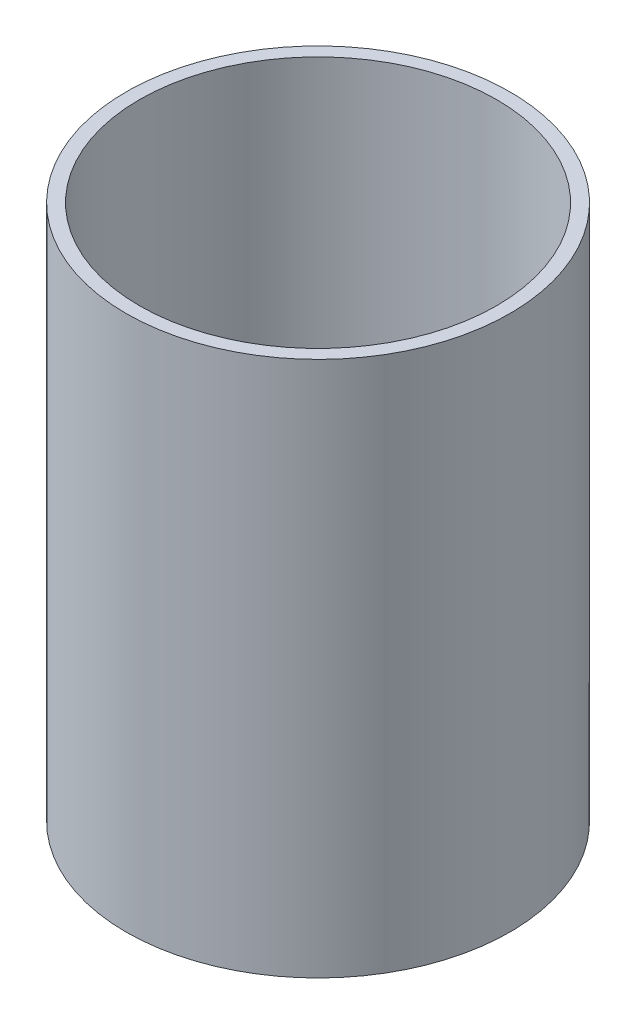
from build123d import *

# Parameters (mm, degrees)
SKETCH2_R           = 27.305
SKETCH2_R_2         = 25.4
BOSS_EXTRUDE1_DEPTH = 76.2


with BuildPart() as part:
    # Sketch2 → Boss-Extrude1 (new body)
    with BuildSketch(Plane(origin=(0, 0, 0), x_dir=(1, 0, 0), z_dir=(0, 1, 0))):
        Circle(SKETCH2_R)
        Circle(SKETCH2_R_2, mode=Mode.SUBTRACT)
    extrude(amount=BOSS_EXTRUDE1_DEPTH)


solid = part.part
